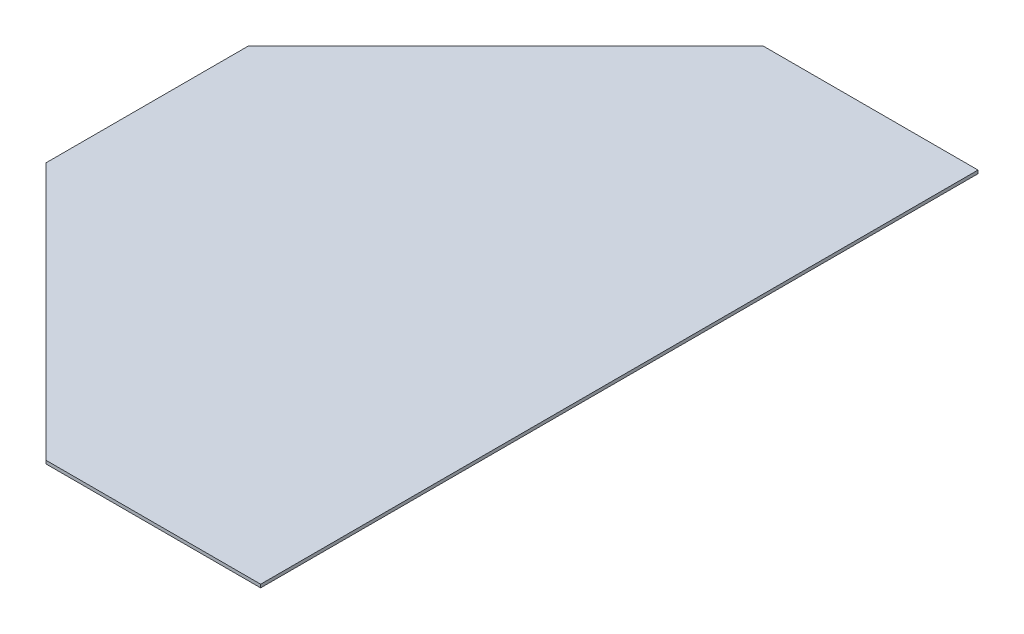
from build123d import *

# Parameters (mm, degrees)
SKETCH1_W           = 440
SKETCH1_H           = 668.38
BOSS_EXTRUDE1_DEPTH = 3
CUT_EXTRUDE1_DEPTH  = 4


with BuildPart() as part:
    # Sketch1 → Boss-Extrude1 (new body)
    with BuildSketch(Plane(origin=(0, 0, 0), x_dir=(1, 0, 0), z_dir=(0, 1, 0))):
        with Locations((220, 334.19)):
            Rectangle(SKETCH1_W, SKETCH1_H)
    extrude(amount=BOSS_EXTRUDE1_DEPTH)

    # Sketch2 → Cut-Extrude1 (cut, through all)
    with BuildSketch(Plane.XZ):
        Polygon((240, 0), (0, -240), (0, 0), align=None)
        Polygon((0, -428.38), (240, -668.38), (0, -668.38), align=None)
    extrude(amount=-CUT_EXTRUDE1_DEPTH, mode=Mode.SUBTRACT)


solid = part.part
